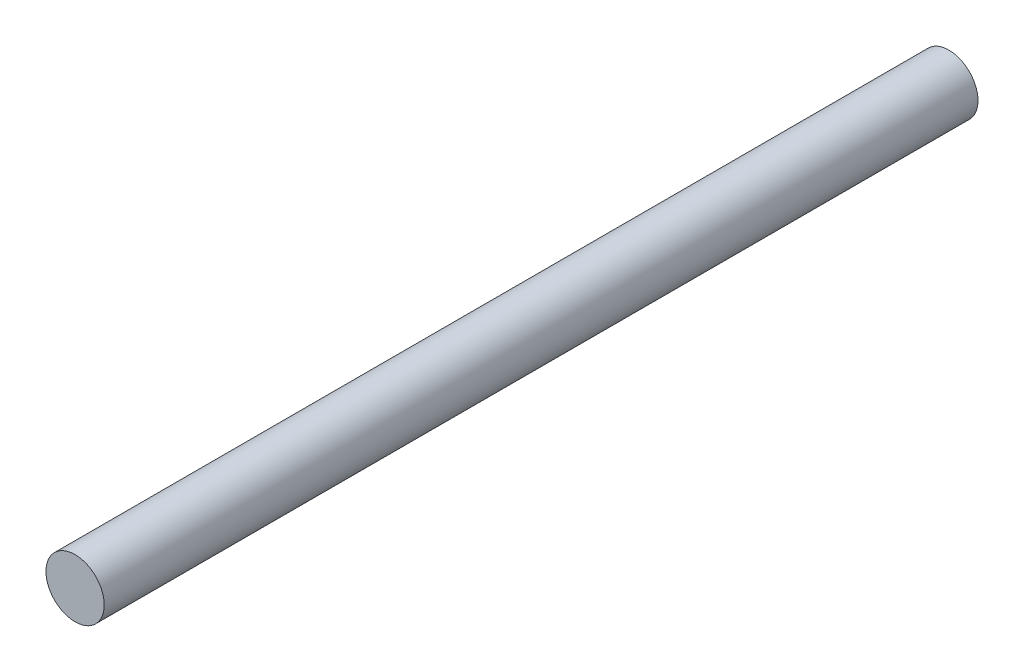
from build123d import *

# Parameters (mm, degrees)
SKETCH1_R           = 2.5
BOSS_EXTRUDE1_DEPTH = 75


with BuildPart() as part:
    # Sketch1 → Boss-Extrude1 (new body)
    with BuildSketch(Plane.XY):
        Circle(SKETCH1_R)
    extrude(amount=BOSS_EXTRUDE1_DEPTH)


solid = part.part
